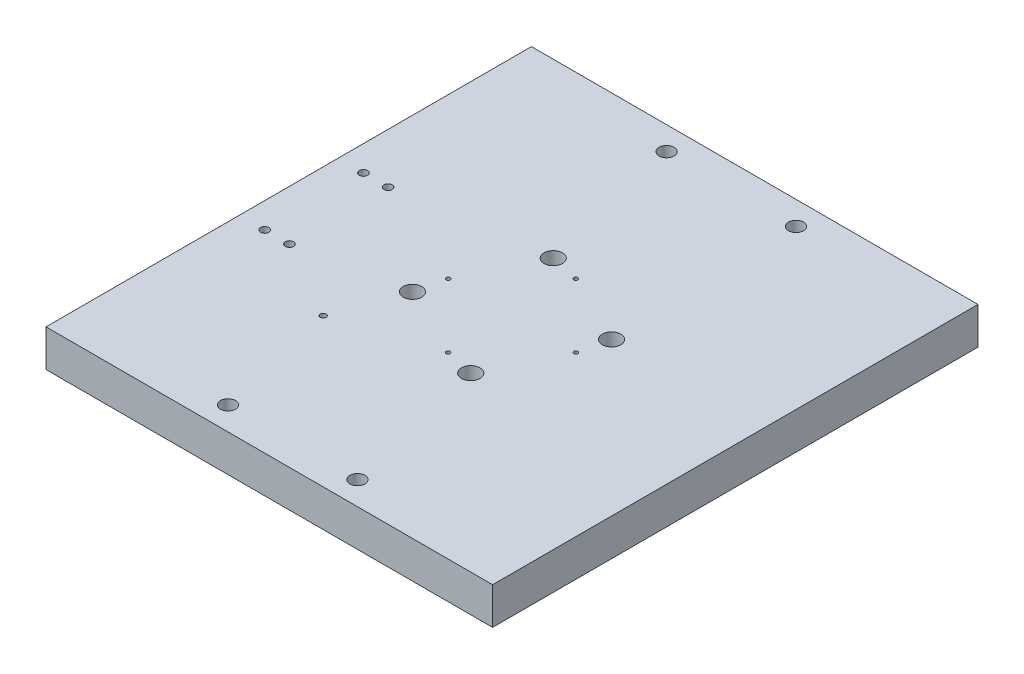
from build123d import *

# Parameters (mm, degrees)
SKETCH1_W                       = 460
SKETCH1_H                       = 500
BOSS_EXTRUDE1_DEPTH             = 38.1
TAP_DRILL_FOR_M5X0_8_TAP1_D     = 4.2
TAP_DRILL_FOR_M5X0_8_TAP1_DEPTH = 20
TAP_DRILL_FOR_M5X0_8_TAP1_TIP   = 1.2618073
F_3_4_0_7500_DOWEL_HOLE1_D      = 19.05
SKETCH13_R                      = 90
CUT_EXTRUDE4_DEPTH              = 15
M14_CLEARANCE_HOLE1_D           = 15.5
TAP_DRILL_FOR_M10X1_5_TAP1_D    = 8.5
F_6_0MM_DOWEL_HOLE1_D           = 6
F_6_0MM_DOWEL_HOLE1_DEPTH       = 10
F_6_0MM_DOWEL_HOLE1_TIP         = 1.802581857


with BuildPart() as part:
    # Sketch1 → Boss-Extrude1 (new body)
    with BuildSketch(Plane(origin=(0, 0, 0), x_dir=(1, 0, 0), z_dir=(0, 1, 0))):
        Rectangle(SKETCH1_W, SKETCH1_H)
    extrude(amount=BOSS_EXTRUDE1_DEPTH)

    # Tap Drill for M5x0.8 Tap1
    with Locations(Plane(origin=(0, 38.1, 0), x_dir=(1, 0, 0), z_dir=(0, 1, 0))):
        with Locations((0, 65.786), (65.786, 0), (0, -65.786), (-65.786, 0)):
            Hole(TAP_DRILL_FOR_M5X0_8_TAP1_D / 2, depth=TAP_DRILL_FOR_M5X0_8_TAP1_DEPTH)
            with Locations((0, 0, -(TAP_DRILL_FOR_M5X0_8_TAP1_DEPTH + TAP_DRILL_FOR_M5X0_8_TAP1_TIP / 2))):  # 118° drill point
                Cone(0, TAP_DRILL_FOR_M5X0_8_TAP1_D / 2, TAP_DRILL_FOR_M5X0_8_TAP1_TIP, mode=Mode.SUBTRACT)

    # 3/4 (0.7500) Dowel Hole1 (through all)
    with Locations(Plane(origin=(0, 0, 0), x_dir=(-1, 0, 0), z_dir=(0, -1, 0))):
        with Locations((72.511608989, -30.035291873), (-30.035291873, -72.511608989), (30.035291873, 72.511608989), (-72.511608989, 30.035291873)):
            Hole(F_3_4_0_7500_DOWEL_HOLE1_D / 2)

    # Sketch13 → Cut-Extrude4 (cut)
    with BuildSketch(Plane.XZ):
        Circle(SKETCH13_R)
    extrude(amount=-CUT_EXTRUDE4_DEPTH, mode=Mode.SUBTRACT)

    # M14 Clearance Hole1 (through all)
    with Locations(Plane(origin=(0, 38.1, 0), x_dir=(1, 0, 0), z_dir=(0, 1, 0))):
        with Locations((66.67, -225.87), (-66.67, -225.87), (-66.67, 225.87), (66.67, 225.87)):
            Hole(M14_CLEARANCE_HOLE1_D / 2)

    # Tap Drill for M10x1.5 Tap1 (through all)
    with Locations(Plane(origin=(0, 0, 0), x_dir=(-1, 0, 0), z_dir=(0, -1, 0))):
        with Locations((178.438, 50.8), (203.838, 50.8), (178.438130466, -50.8), (203.838, -50.881410466)):
            Hole(TAP_DRILL_FOR_M10X1_5_TAP1_D / 2)

    # Ø6.0mm Dowel Hole1
    with Locations(Plane(origin=(0, 38.1, 0), x_dir=(1, 0, 0), z_dir=(0, 1, 0))):
        with Locations((-97.227182413, -97.227182413)):
            Hole(F_6_0MM_DOWEL_HOLE1_D / 2, depth=F_6_0MM_DOWEL_HOLE1_DEPTH)
            with Locations((0, 0, -(F_6_0MM_DOWEL_HOLE1_DEPTH + F_6_0MM_DOWEL_HOLE1_TIP / 2))):  # 118° drill point
                Cone(0, F_6_0MM_DOWEL_HOLE1_D / 2, F_6_0MM_DOWEL_HOLE1_TIP, mode=Mode.SUBTRACT)


solid = part.part
